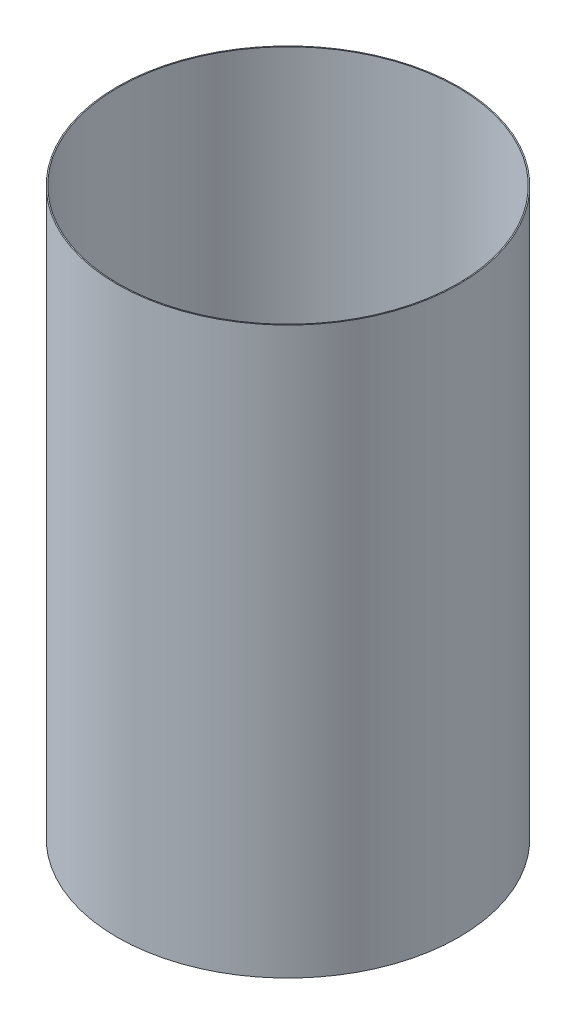
from build123d import *

# Parameters (mm, degrees)
SKETCH1_W = 0.254
SKETCH1_H = 133.35


with BuildPart() as part:
    # Sketch1 → Revolve-Thin1 (revolve)
    with BuildSketch(Plane.XY):
        with Locations((-40.1955, -135.67819341)):
            Rectangle(SKETCH1_W, SKETCH1_H)
    revolve(axis=Axis((0, 55, 0), (0, -1, 0)))


solid = part.part
